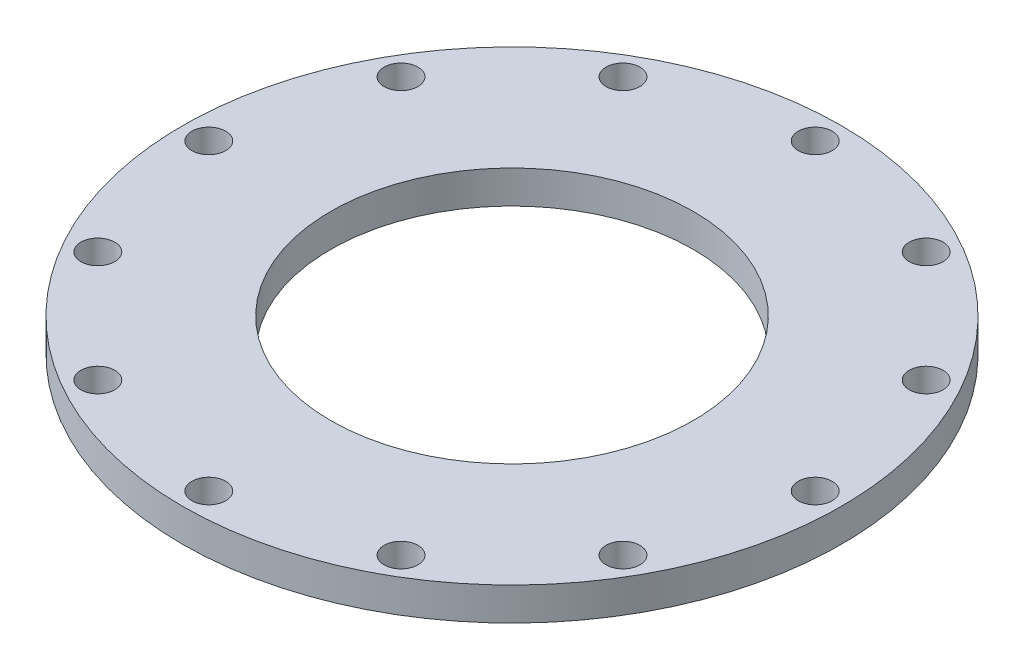
from build123d import *

# Parameters (mm, degrees)
SKETCH1_R           = 63.5
SKETCH1_R_2         = 34.925
SKETCH1_R_3         = 3.2639
BOSS_EXTRUDE1_DEPTH = 6.35


with BuildPart() as part:
    # Sketch1 → Boss-Extrude1 (new body)
    with BuildSketch(Plane(origin=(0, 0, 0), x_dir=(1, 0, 0), z_dir=(0, 1, 0))):
        Circle(SKETCH1_R)
        Circle(SKETCH1_R_2, mode=Mode.SUBTRACT)
        with Locations((0, 58.42)):
            Circle(SKETCH1_R_3, mode=Mode.SUBTRACT)
        with Locations((29.21, 50.593204089)):
            Circle(SKETCH1_R_3, mode=Mode.SUBTRACT)
        with Locations((50.593204089, 29.21)):
            Circle(SKETCH1_R_3, mode=Mode.SUBTRACT)
        with Locations((58.42, 0)):
            Circle(SKETCH1_R_3, mode=Mode.SUBTRACT)
        with Locations((50.593204089, -29.21)):
            Circle(SKETCH1_R_3, mode=Mode.SUBTRACT)
        with Locations((29.21, -50.593204089)):
            Circle(SKETCH1_R_3, mode=Mode.SUBTRACT)
        with Locations((0, -58.42)):
            Circle(SKETCH1_R_3, mode=Mode.SUBTRACT)
        with Locations((-29.21, -50.593204089)):
            Circle(SKETCH1_R_3, mode=Mode.SUBTRACT)
        with Locations((-50.593204089, -29.21)):
            Circle(SKETCH1_R_3, mode=Mode.SUBTRACT)
        with Locations((-58.42, 0)):
            Circle(SKETCH1_R_3, mode=Mode.SUBTRACT)
        with Locations((-50.593204089, 29.21)):
            Circle(SKETCH1_R_3, mode=Mode.SUBTRACT)
        with Locations((-29.21, 50.593204089)):
            Circle(SKETCH1_R_3, mode=Mode.SUBTRACT)
    extrude(amount=BOSS_EXTRUDE1_DEPTH)


solid = part.part
